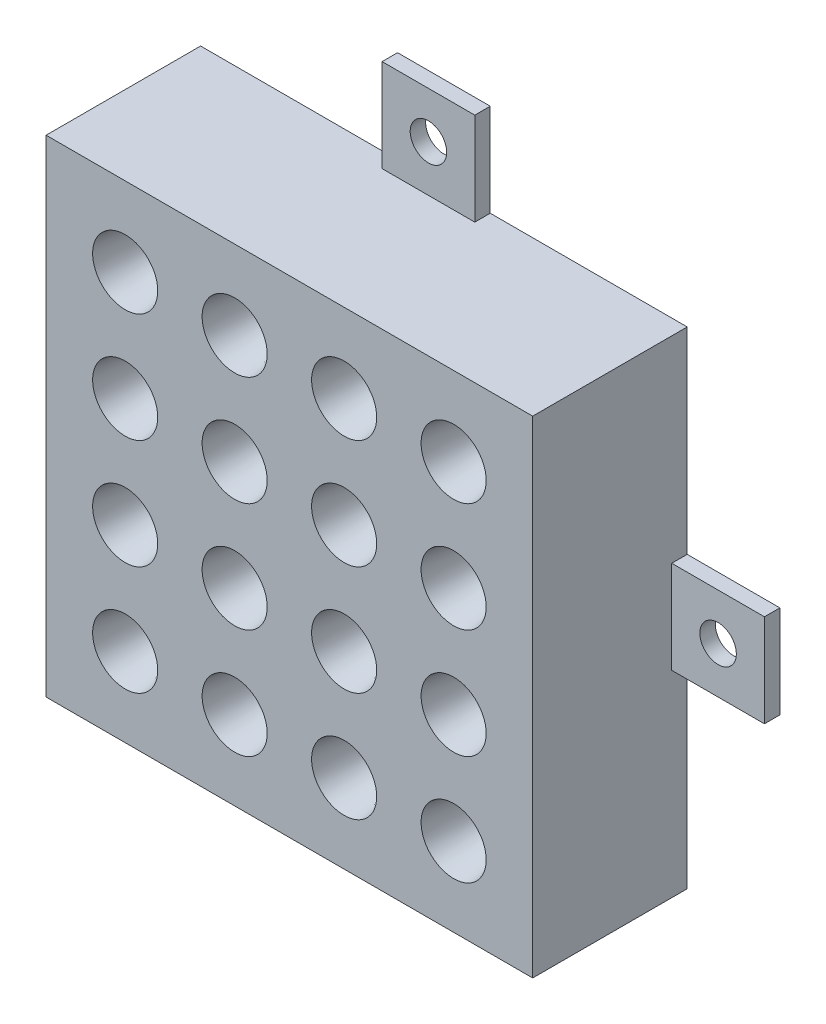
from build123d import *

# Parameters (mm, degrees)
SKETCH1_W                     = 40
SKETCH1_H                     = 40
BOSS_EXTRUDE1_DEPTH           = 12.7
SKETCH2_R                     = 2.67558437
CUT_EXTRUDE1_DEPTH            = 11.176
CUT_EXTRUDE1_DRAFT            = -8.75
CUT_EXTRUDE1_PROFILE_2_DEPTH  = 11.176
CUT_EXTRUDE1_PROFILE_2_DRAFT  = -8.75
CUT_EXTRUDE1_PROFILE_3_DEPTH  = 11.176
CUT_EXTRUDE1_PROFILE_3_DRAFT  = -8.75
CUT_EXTRUDE1_PROFILE_4_DEPTH  = 11.176
CUT_EXTRUDE1_PROFILE_4_DRAFT  = -8.75
CUT_EXTRUDE1_PROFILE_5_DEPTH  = 11.176
CUT_EXTRUDE1_PROFILE_5_DRAFT  = -8.75
CUT_EXTRUDE1_PROFILE_6_DEPTH  = 11.176
CUT_EXTRUDE1_PROFILE_6_DRAFT  = -8.75
CUT_EXTRUDE1_PROFILE_7_DEPTH  = 11.176
CUT_EXTRUDE1_PROFILE_7_DRAFT  = -8.75
CUT_EXTRUDE1_PROFILE_8_DEPTH  = 11.176
CUT_EXTRUDE1_PROFILE_8_DRAFT  = -8.75
CUT_EXTRUDE1_PROFILE_9_DEPTH  = 11.176
CUT_EXTRUDE1_PROFILE_9_DRAFT  = -8.75
CUT_EXTRUDE1_PROFILE_10_DEPTH = 11.176
CUT_EXTRUDE1_PROFILE_10_DRAFT = -8.75
CUT_EXTRUDE1_PROFILE_11_DEPTH = 11.176
CUT_EXTRUDE1_PROFILE_11_DRAFT = -8.75
CUT_EXTRUDE1_PROFILE_12_DEPTH = 11.176
CUT_EXTRUDE1_PROFILE_12_DRAFT = -8.75
CUT_EXTRUDE1_PROFILE_13_DEPTH = 11.176
CUT_EXTRUDE1_PROFILE_13_DRAFT = -8.75
CUT_EXTRUDE1_PROFILE_14_DEPTH = 11.176
CUT_EXTRUDE1_PROFILE_14_DRAFT = -8.75
CUT_EXTRUDE1_PROFILE_15_DEPTH = 11.176
CUT_EXTRUDE1_PROFILE_15_DRAFT = -8.75
CUT_EXTRUDE1_PROFILE_16_DEPTH = 11.176
CUT_EXTRUDE1_PROFILE_16_DRAFT = -8.75
SKETCH3_W                     = 7.62
SKETCH3_H                     = 1.27
BOSS_EXTRUDE2_DEPTH           = 7.62
SKETCH4_W                     = 1.27
SKETCH4_H                     = 7.62
BOSS_EXTRUDE3_DEPTH           = 7.62
SKETCH5_W                     = 1.27
SKETCH5_H                     = 7.62
BOSS_EXTRUDE4_DEPTH           = 7.62
SKETCH6_W                     = 7.62
SKETCH6_H                     = 1.27
BOSS_EXTRUDE5_DEPTH           = 7.62
SKETCH7_R                     = 1.5
M3_DIAMETER_HOLES_DEPTH       = 7.62
SKETCH8_R                     = 0.4572
SKETCH8_R_2                   = 0.02667
CUT_EXTRUDE3_DEPTH            = 2


with BuildPart() as part:
    # Sketch1 → Boss-Extrude1 (new body)
    with BuildSketch(Plane.XY):
        with Locations((-32.473746891, -5.437780853)):
            Rectangle(SKETCH1_W, SKETCH1_H)
    extrude(amount=BOSS_EXTRUDE1_DEPTH)


with BuildPart() as cut_extrude1_tool:
    # Sketch2 → Cut-Extrude1 (with draft: the straight prism first)
    with BuildSketch(Plane.XY.offset(12.7)):
        with Locations((-45.973746891, 8.062219147)):
            Circle(SKETCH2_R)
    extrude(amount=-CUT_EXTRUDE1_DEPTH)
    # Cut-Extrude1: the draft: its side faces are tilted about the plane it starts from
    cut_extrude1_sides = [cut_extrude1_tool.faces().sort_by_distance(p)[0] for p in [
        (-48.649331261, 8.062219147, 7.112),
    ]]
    draft(cut_extrude1_sides, Plane.XY.offset(12.7), CUT_EXTRUDE1_DRAFT)


with BuildPart() as part_1:
    add(part.part)

    # Cut-Extrude1: cut by cut_extrude1_tool
    add(cut_extrude1_tool.part, mode=Mode.SUBTRACT)


with BuildPart() as cut_extrude1_profile_2_tool:
    # Sketch2 → Cut-Extrude1 profile 2 (with draft: the straight prism first)
    with BuildSketch(Plane.XY.offset(12.7)):
        with Locations((-36.973746891, 8.062219147)):
            Circle(SKETCH2_R)
    extrude(amount=-CUT_EXTRUDE1_PROFILE_2_DEPTH)
    # Cut-Extrude1 profile 2: the draft: its side faces are tilted about the plane it starts from
    cut_extrude1_profile_2_sides = [cut_extrude1_profile_2_tool.faces().sort_by_distance(p)[0] for p in [
        (-39.649331261, 8.062219147, 7.112),
    ]]
    draft(cut_extrude1_profile_2_sides, Plane.XY.offset(12.7), CUT_EXTRUDE1_PROFILE_2_DRAFT)


with BuildPart() as part_2:
    add(part_1.part)

    # Cut-Extrude1 profile 2: cut by cut_extrude1_profile_2_tool
    add(cut_extrude1_profile_2_tool.part, mode=Mode.SUBTRACT)


with BuildPart() as cut_extrude1_profile_3_tool:
    # Sketch2 → Cut-Extrude1 profile 3 (with draft: the straight prism first)
    with BuildSketch(Plane.XY.offset(12.7)):
        with Locations((-27.973746891, 8.062219147)):
            Circle(SKETCH2_R)
    extrude(amount=-CUT_EXTRUDE1_PROFILE_3_DEPTH)
    # Cut-Extrude1 profile 3: the draft: its side faces are tilted about the plane it starts from
    cut_extrude1_profile_3_sides = [cut_extrude1_profile_3_tool.faces().sort_by_distance(p)[0] for p in [
        (-30.649331261, 8.062219147, 7.112),
    ]]
    draft(cut_extrude1_profile_3_sides, Plane.XY.offset(12.7), CUT_EXTRUDE1_PROFILE_3_DRAFT)


with BuildPart() as part_3:
    add(part_2.part)

    # Cut-Extrude1 profile 3: cut by cut_extrude1_profile_3_tool
    add(cut_extrude1_profile_3_tool.part, mode=Mode.SUBTRACT)


with BuildPart() as cut_extrude1_profile_4_tool:
    # Sketch2 → Cut-Extrude1 profile 4 (with draft: the straight prism first)
    with BuildSketch(Plane.XY.offset(12.7)):
        with Locations((-18.973746891, 8.062219147)):
            Circle(SKETCH2_R)
    extrude(amount=-CUT_EXTRUDE1_PROFILE_4_DEPTH)
    # Cut-Extrude1 profile 4: the draft: its side faces are tilted about the plane it starts from
    cut_extrude1_profile_4_sides = [cut_extrude1_profile_4_tool.faces().sort_by_distance(p)[0] for p in [
        (-21.649331261, 8.062219147, 7.112),
    ]]
    draft(cut_extrude1_profile_4_sides, Plane.XY.offset(12.7), CUT_EXTRUDE1_PROFILE_4_DRAFT)


with BuildPart() as part_4:
    add(part_3.part)

    # Cut-Extrude1 profile 4: cut by cut_extrude1_profile_4_tool
    add(cut_extrude1_profile_4_tool.part, mode=Mode.SUBTRACT)


with BuildPart() as cut_extrude1_profile_5_tool:
    # Sketch2 → Cut-Extrude1 profile 5 (with draft: the straight prism first)
    with BuildSketch(Plane.XY.offset(12.7)):
        with Locations((-45.973746891, -0.937780853)):
            Circle(SKETCH2_R)
    extrude(amount=-CUT_EXTRUDE1_PROFILE_5_DEPTH)
    # Cut-Extrude1 profile 5: the draft: its side faces are tilted about the plane it starts from
    cut_extrude1_profile_5_sides = [cut_extrude1_profile_5_tool.faces().sort_by_distance(p)[0] for p in [
        (-48.649331261, -0.937780853, 7.112),
    ]]
    draft(cut_extrude1_profile_5_sides, Plane.XY.offset(12.7), CUT_EXTRUDE1_PROFILE_5_DRAFT)


with BuildPart() as part_5:
    add(part_4.part)

    # Cut-Extrude1 profile 5: cut by cut_extrude1_profile_5_tool
    add(cut_extrude1_profile_5_tool.part, mode=Mode.SUBTRACT)


with BuildPart() as cut_extrude1_profile_6_tool:
    # Sketch2 → Cut-Extrude1 profile 6 (with draft: the straight prism first)
    with BuildSketch(Plane.XY.offset(12.7)):
        with Locations((-36.973746891, -0.937780853)):
            Circle(SKETCH2_R)
    extrude(amount=-CUT_EXTRUDE1_PROFILE_6_DEPTH)
    # Cut-Extrude1 profile 6: the draft: its side faces are tilted about the plane it starts from
    cut_extrude1_profile_6_sides = [cut_extrude1_profile_6_tool.faces().sort_by_distance(p)[0] for p in [
        (-39.649331261, -0.937780853, 7.112),
    ]]
    draft(cut_extrude1_profile_6_sides, Plane.XY.offset(12.7), CUT_EXTRUDE1_PROFILE_6_DRAFT)


with BuildPart() as part_6:
    add(part_5.part)

    # Cut-Extrude1 profile 6: cut by cut_extrude1_profile_6_tool
    add(cut_extrude1_profile_6_tool.part, mode=Mode.SUBTRACT)


with BuildPart() as cut_extrude1_profile_7_tool:
    # Sketch2 → Cut-Extrude1 profile 7 (with draft: the straight prism first)
    with BuildSketch(Plane.XY.offset(12.7)):
        with Locations((-27.973746891, -0.937780853)):
            Circle(SKETCH2_R)
    extrude(amount=-CUT_EXTRUDE1_PROFILE_7_DEPTH)
    # Cut-Extrude1 profile 7: the draft: its side faces are tilted about the plane it starts from
    cut_extrude1_profile_7_sides = [cut_extrude1_profile_7_tool.faces().sort_by_distance(p)[0] for p in [
        (-30.649331261, -0.937780853, 7.112),
    ]]
    draft(cut_extrude1_profile_7_sides, Plane.XY.offset(12.7), CUT_EXTRUDE1_PROFILE_7_DRAFT)


with BuildPart() as part_7:
    add(part_6.part)

    # Cut-Extrude1 profile 7: cut by cut_extrude1_profile_7_tool
    add(cut_extrude1_profile_7_tool.part, mode=Mode.SUBTRACT)


with BuildPart() as cut_extrude1_profile_8_tool:
    # Sketch2 → Cut-Extrude1 profile 8 (with draft: the straight prism first)
    with BuildSketch(Plane.XY.offset(12.7)):
        with Locations((-18.973746891, -0.937780853)):
            Circle(SKETCH2_R)
    extrude(amount=-CUT_EXTRUDE1_PROFILE_8_DEPTH)
    # Cut-Extrude1 profile 8: the draft: its side faces are tilted about the plane it starts from
    cut_extrude1_profile_8_sides = [cut_extrude1_profile_8_tool.faces().sort_by_distance(p)[0] for p in [
        (-21.649331261, -0.937780853, 7.112),
    ]]
    draft(cut_extrude1_profile_8_sides, Plane.XY.offset(12.7), CUT_EXTRUDE1_PROFILE_8_DRAFT)


with BuildPart() as part_8:
    add(part_7.part)

    # Cut-Extrude1 profile 8: cut by cut_extrude1_profile_8_tool
    add(cut_extrude1_profile_8_tool.part, mode=Mode.SUBTRACT)


with BuildPart() as cut_extrude1_profile_9_tool:
    # Sketch2 → Cut-Extrude1 profile 9 (with draft: the straight prism first)
    with BuildSketch(Plane.XY.offset(12.7)):
        with Locations((-45.973746891, -9.937780853)):
            Circle(SKETCH2_R)
    extrude(amount=-CUT_EXTRUDE1_PROFILE_9_DEPTH)
    # Cut-Extrude1 profile 9: the draft: its side faces are tilted about the plane it starts from
    cut_extrude1_profile_9_sides = [cut_extrude1_profile_9_tool.faces().sort_by_distance(p)[0] for p in [
        (-48.649331261, -9.937780853, 7.112),
    ]]
    draft(cut_extrude1_profile_9_sides, Plane.XY.offset(12.7), CUT_EXTRUDE1_PROFILE_9_DRAFT)


with BuildPart() as part_9:
    add(part_8.part)

    # Cut-Extrude1 profile 9: cut by cut_extrude1_profile_9_tool
    add(cut_extrude1_profile_9_tool.part, mode=Mode.SUBTRACT)


with BuildPart() as cut_extrude1_profile_10_tool:
    # Sketch2 → Cut-Extrude1 profile 10 (with draft: the straight prism first)
    with BuildSketch(Plane.XY.offset(12.7)):
        with Locations((-36.973746891, -9.937780853)):
            Circle(SKETCH2_R)
    extrude(amount=-CUT_EXTRUDE1_PROFILE_10_DEPTH)
    # Cut-Extrude1 profile 10: the draft: its side faces are tilted about the plane it starts from
    cut_extrude1_profile_10_sides = [cut_extrude1_profile_10_tool.faces().sort_by_distance(p)[0] for p in [
        (-39.649331261, -9.937780853, 7.112),
    ]]
    draft(cut_extrude1_profile_10_sides, Plane.XY.offset(12.7), CUT_EXTRUDE1_PROFILE_10_DRAFT)


with BuildPart() as part_10:
    add(part_9.part)

    # Cut-Extrude1 profile 10: cut by cut_extrude1_profile_10_tool
    add(cut_extrude1_profile_10_tool.part, mode=Mode.SUBTRACT)


with BuildPart() as cut_extrude1_profile_11_tool:
    # Sketch2 → Cut-Extrude1 profile 11 (with draft: the straight prism first)
    with BuildSketch(Plane.XY.offset(12.7)):
        with Locations((-27.973746891, -9.937780853)):
            Circle(SKETCH2_R)
    extrude(amount=-CUT_EXTRUDE1_PROFILE_11_DEPTH)
    # Cut-Extrude1 profile 11: the draft: its side faces are tilted about the plane it starts from
    cut_extrude1_profile_11_sides = [cut_extrude1_profile_11_tool.faces().sort_by_distance(p)[0] for p in [
        (-30.649331261, -9.937780853, 7.112),
    ]]
    draft(cut_extrude1_profile_11_sides, Plane.XY.offset(12.7), CUT_EXTRUDE1_PROFILE_11_DRAFT)


with BuildPart() as part_11:
    add(part_10.part)

    # Cut-Extrude1 profile 11: cut by cut_extrude1_profile_11_tool
    add(cut_extrude1_profile_11_tool.part, mode=Mode.SUBTRACT)


with BuildPart() as cut_extrude1_profile_12_tool:
    # Sketch2 → Cut-Extrude1 profile 12 (with draft: the straight prism first)
    with BuildSketch(Plane.XY.offset(12.7)):
        with Locations((-18.973746891, -9.937780853)):
            Circle(SKETCH2_R)
    extrude(amount=-CUT_EXTRUDE1_PROFILE_12_DEPTH)
    # Cut-Extrude1 profile 12: the draft: its side faces are tilted about the plane it starts from
    cut_extrude1_profile_12_sides = [cut_extrude1_profile_12_tool.faces().sort_by_distance(p)[0] for p in [
        (-21.649331261, -9.937780853, 7.112),
    ]]
    draft(cut_extrude1_profile_12_sides, Plane.XY.offset(12.7), CUT_EXTRUDE1_PROFILE_12_DRAFT)


with BuildPart() as part_12:
    add(part_11.part)

    # Cut-Extrude1 profile 12: cut by cut_extrude1_profile_12_tool
    add(cut_extrude1_profile_12_tool.part, mode=Mode.SUBTRACT)


with BuildPart() as cut_extrude1_profile_13_tool:
    # Sketch2 → Cut-Extrude1 profile 13 (with draft: the straight prism first)
    with BuildSketch(Plane.XY.offset(12.7)):
        with Locations((-45.973746891, -18.937780853)):
            Circle(SKETCH2_R)
    extrude(amount=-CUT_EXTRUDE1_PROFILE_13_DEPTH)
    # Cut-Extrude1 profile 13: the draft: its side faces are tilted about the plane it starts from
    cut_extrude1_profile_13_sides = [cut_extrude1_profile_13_tool.faces().sort_by_distance(p)[0] for p in [
        (-48.649331261, -18.937780853, 7.112),
    ]]
    draft(cut_extrude1_profile_13_sides, Plane.XY.offset(12.7), CUT_EXTRUDE1_PROFILE_13_DRAFT)


with BuildPart() as part_13:
    add(part_12.part)

    # Cut-Extrude1 profile 13: cut by cut_extrude1_profile_13_tool
    add(cut_extrude1_profile_13_tool.part, mode=Mode.SUBTRACT)


with BuildPart() as cut_extrude1_profile_14_tool:
    # Sketch2 → Cut-Extrude1 profile 14 (with draft: the straight prism first)
    with BuildSketch(Plane.XY.offset(12.7)):
        with Locations((-36.973746891, -18.937780853)):
            Circle(SKETCH2_R)
    extrude(amount=-CUT_EXTRUDE1_PROFILE_14_DEPTH)
    # Cut-Extrude1 profile 14: the draft: its side faces are tilted about the plane it starts from
    cut_extrude1_profile_14_sides = [cut_extrude1_profile_14_tool.faces().sort_by_distance(p)[0] for p in [
        (-39.649331261, -18.937780853, 7.112),
    ]]
    draft(cut_extrude1_profile_14_sides, Plane.XY.offset(12.7), CUT_EXTRUDE1_PROFILE_14_DRAFT)


with BuildPart() as part_14:
    add(part_13.part)

    # Cut-Extrude1 profile 14: cut by cut_extrude1_profile_14_tool
    add(cut_extrude1_profile_14_tool.part, mode=Mode.SUBTRACT)


with BuildPart() as cut_extrude1_profile_15_tool:
    # Sketch2 → Cut-Extrude1 profile 15 (with draft: the straight prism first)
    with BuildSketch(Plane.XY.offset(12.7)):
        with Locations((-27.973746891, -18.937780853)):
            Circle(SKETCH2_R)
    extrude(amount=-CUT_EXTRUDE1_PROFILE_15_DEPTH)
    # Cut-Extrude1 profile 15: the draft: its side faces are tilted about the plane it starts from
    cut_extrude1_profile_15_sides = [cut_extrude1_profile_15_tool.faces().sort_by_distance(p)[0] for p in [
        (-30.649331261, -18.937780853, 7.112),
    ]]
    draft(cut_extrude1_profile_15_sides, Plane.XY.offset(12.7), CUT_EXTRUDE1_PROFILE_15_DRAFT)


with BuildPart() as part_15:
    add(part_14.part)

    # Cut-Extrude1 profile 15: cut by cut_extrude1_profile_15_tool
    add(cut_extrude1_profile_15_tool.part, mode=Mode.SUBTRACT)


with BuildPart() as cut_extrude1_profile_16_tool:
    # Sketch2 → Cut-Extrude1 profile 16 (with draft: the straight prism first)
    with BuildSketch(Plane.XY.offset(12.7)):
        with Locations((-18.973746891, -18.937780853)):
            Circle(SKETCH2_R)
    extrude(amount=-CUT_EXTRUDE1_PROFILE_16_DEPTH)
    # Cut-Extrude1 profile 16: the draft: its side faces are tilted about the plane it starts from
    cut_extrude1_profile_16_sides = [cut_extrude1_profile_16_tool.faces().sort_by_distance(p)[0] for p in [
        (-21.649331261, -18.937780853, 7.112),
    ]]
    draft(cut_extrude1_profile_16_sides, Plane.XY.offset(12.7), CUT_EXTRUDE1_PROFILE_16_DRAFT)


with BuildPart() as part_16:
    add(part_15.part)

    # Cut-Extrude1 profile 16: cut by cut_extrude1_profile_16_tool
    add(cut_extrude1_profile_16_tool.part, mode=Mode.SUBTRACT)

    # Sketch3 → Boss-Extrude2 (add)
    with BuildSketch(Plane(origin=(0, 14.562219147, 0), x_dir=(1, 0, 0), z_dir=(0, 1, 0))):
        with Locations((-32.473706891, -0.635)):
            Rectangle(SKETCH3_W, SKETCH3_H)
    extrude(amount=BOSS_EXTRUDE2_DEPTH)

    # Sketch4 → Boss-Extrude3 (add)
    with BuildSketch(Plane(origin=(-12.473746891, 0, 0), x_dir=(0, 0, -1), z_dir=(1, 0, 0))):
        with Locations((-0.635, -5.437820853)):
            Rectangle(SKETCH4_W, SKETCH4_H)
    extrude(amount=BOSS_EXTRUDE3_DEPTH)

    # Sketch5 → Boss-Extrude4 (add)
    with BuildSketch(Plane.ZY.offset(52.473746891)):
        with Locations((0.635, -5.437740853)):
            Rectangle(SKETCH5_W, SKETCH5_H)
    extrude(amount=BOSS_EXTRUDE4_DEPTH)

    # Sketch6 → Boss-Extrude5 (add)
    with BuildSketch(Plane.XZ.offset(25.437780853)):
        with Locations((-32.473786891, 0.635)):
            Rectangle(SKETCH6_W, SKETCH6_H)
    extrude(amount=BOSS_EXTRUDE5_DEPTH)

    # Sketch7 → M3 diameter holes (cut)
    with BuildSketch(Plane.XY.offset(1.27)):
        with Locations((-32.473786891, -29.247780853)):
            Circle(SKETCH7_R)
        with Locations((-56.283746891, -5.437740853)):
            Circle(SKETCH7_R)
        with Locations((-8.663746891, -5.437820853)):
            Circle(SKETCH7_R)
        with Locations((-32.473706891, 18.372219147)):
            Circle(SKETCH7_R)
    extrude(amount=-M3_DIAMETER_HOLES_DEPTH, mode=Mode.SUBTRACT)

    # Sketch15 → 64 _0.036_ Diameter Hole1 (revolve, cut)
    with BuildSketch(Plane(origin=(-32.473746891, -25.437780853, 5.08), x_dir=(0, 0.2588190451025215, -0.9659258262890681), z_dir=(1, 0, 0))):
        Polygon((0, 0), (0, 7.874713475), (0.4572, 7.6), (0.4572, 0), align=None)
    revolve(axis=Axis((-32.473746891, -31.57140985, 3.436499064), (0, 0.9659258262890682, 0.2588190451025215)), mode=Mode.SUBTRACT)

    # Sketch8 → Cut-Extrude3 (cut, along a direction that is not the sketch's normal)
    with BuildSketch(Plane.XZ.offset(25.437780853)):
        with Locations((-32.473746891, 5.08)):
            Circle(SKETCH8_R)
        with Locations((-32.473746891, 5.08)):
            Circle(SKETCH8_R_2, mode=Mode.SUBTRACT)
    extrude(amount=-CUT_EXTRUDE3_DEPTH, dir=(0, -0.9659258262890681, -0.2588190451025215), mode=Mode.SUBTRACT)


with BuildPart() as cut_extrude3_piece_1:
    # of the separate pieces the step leaves, piece 1, a body of its own (cut_extrude3_pieces)
    add(part_16.part.solids().sort_by_distance((-52.473746891, 14.562219147, 0))[0])


with BuildPart() as cut_extrude3_piece_2:
    # of the separate pieces the step leaves, piece 2, a body of its own (cut_extrude3_pieces)
    add(part_16.part.solids().sort_by_distance((-32.500416891, -25.437780853, 5.08))[0])


solid = Compound([cut_extrude3_piece_1.part, cut_extrude3_piece_2.part])
